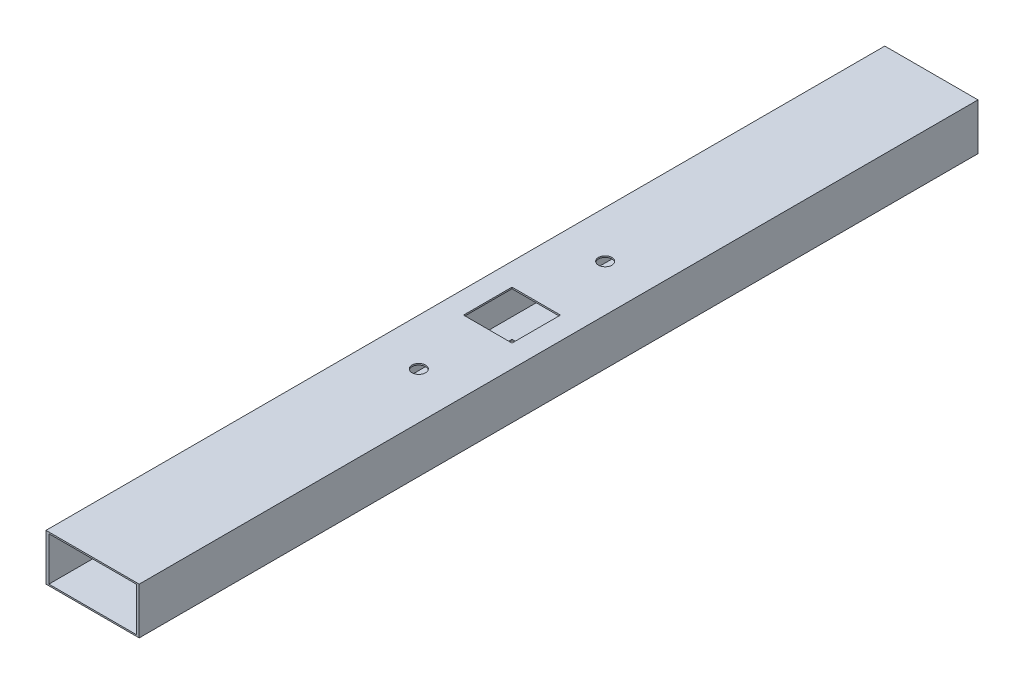
from build123d import *

# Parameters (mm, degrees)
SKETCH1_W           = 50.8
SKETCH1_H           = 25.4
SKETCH1_W_2         = 47.625
SKETCH1_H_2         = 23.8125
BOSS_EXTRUDE1_DEPTH = 457.2
SKETCH2_R           = 3.683
SKETCH2_W           = 26.416
SKETCH2_H           = 26.416
CUT_EXTRUDE1_DEPTH  = 26.4


with BuildPart() as part:
    # Sketch1 → Boss-Extrude1 (new body)
    with BuildSketch(Plane.XY):
        Rectangle(SKETCH1_W, SKETCH1_H)
        Rectangle(SKETCH1_W_2, SKETCH1_H_2, mode=Mode.SUBTRACT)
    extrude(amount=BOSS_EXTRUDE1_DEPTH)

    # Sketch2 → Cut-Extrude1 (cut, through all)
    with BuildSketch(Plane(origin=(0, 12.7, 0), x_dir=(1, 0, 0), z_dir=(0, 1, 0))):
        with Locations((0, -177.8)):
            Circle(SKETCH2_R)
        with Locations((0, -279.4)):
            Circle(SKETCH2_R)
        with Locations((0, -228.6)):
            Rectangle(SKETCH2_W, SKETCH2_H)
    extrude(amount=-CUT_EXTRUDE1_DEPTH, mode=Mode.SUBTRACT)


solid = part.part
